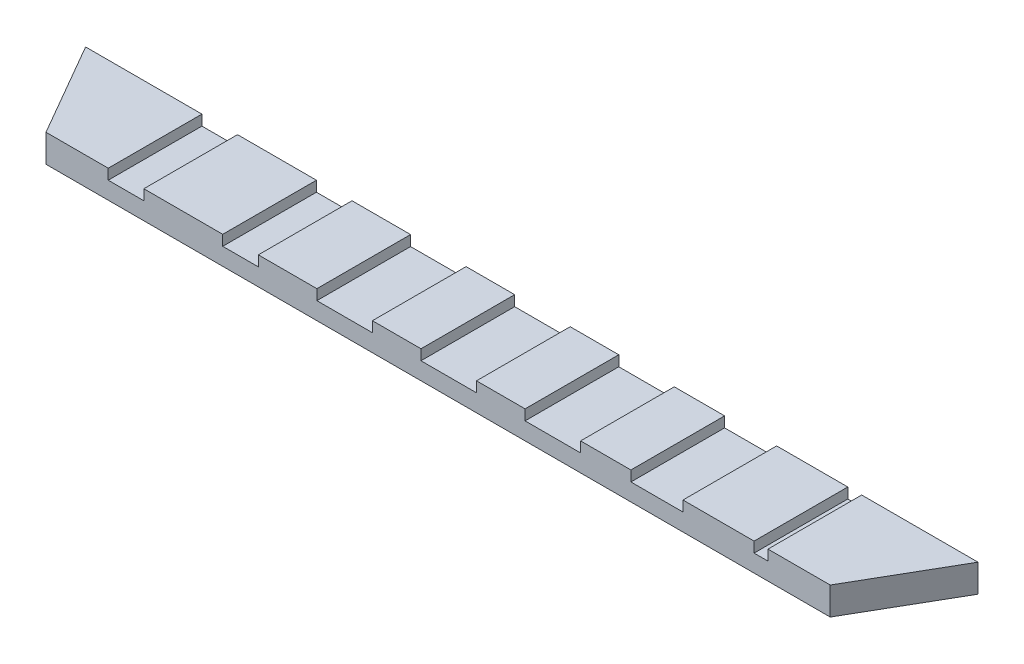
from build123d import *

# Parameters (mm, degrees)
BOSS_EXTRUDE1_DEPTH = 8
SKETCH4_W           = 10.258234737
SKETCH4_H           = 27
SKETCH4_W_2         = 16
SKETCH4_W_3         = 15
SKETCH4_W_4         = 4
CUT_EXTRUDE1_DEPTH  = 3


with BuildPart() as part:
    # Sketch1 → Boss-Extrude1 (new body)
    with BuildSketch(Plane(origin=(0, 0, 0), x_dir=(1, 0, 0), z_dir=(0, 1, 0))):
        Polygon((-113, -12.62891462), (113, -12.62891462), (128.588457268, 14.37108538), (-128.588457268, 14.37108538), align=None)
    extrude(amount=BOSS_EXTRUDE1_DEPTH)

    # Sketch4 → Cut-Extrude1 (cut)
    with BuildSketch(Plane(origin=(0, 8, 0), x_dir=(1, 0, 0), z_dir=(0, 1, 0))):
        with Locations((-56.935441316, 0.87108538)):
            Rectangle(SKETCH4_W, SKETCH4_H)
        with Locations((-89.935441316, 0.87108538)):
            Rectangle(SKETCH4_W, SKETCH4_H)
        with Locations((-26.935441316, 0.87108538)):
            Rectangle(SKETCH4_W_2, SKETCH4_H)
        with Locations((3.064558684, 0.87108538)):
            Rectangle(SKETCH4_W_2, SKETCH4_H)
        with Locations((33.064558684, 0.87108538)):
            Rectangle(SKETCH4_W_2, SKETCH4_H)
        with Locations((63.064558684, 0.87108538)):
            Rectangle(SKETCH4_W_3, SKETCH4_H)
        with Locations((93.064558684, 0.87108538)):
            Rectangle(SKETCH4_W_4, SKETCH4_H)
    extrude(amount=-CUT_EXTRUDE1_DEPTH, mode=Mode.SUBTRACT)


solid = part.part
